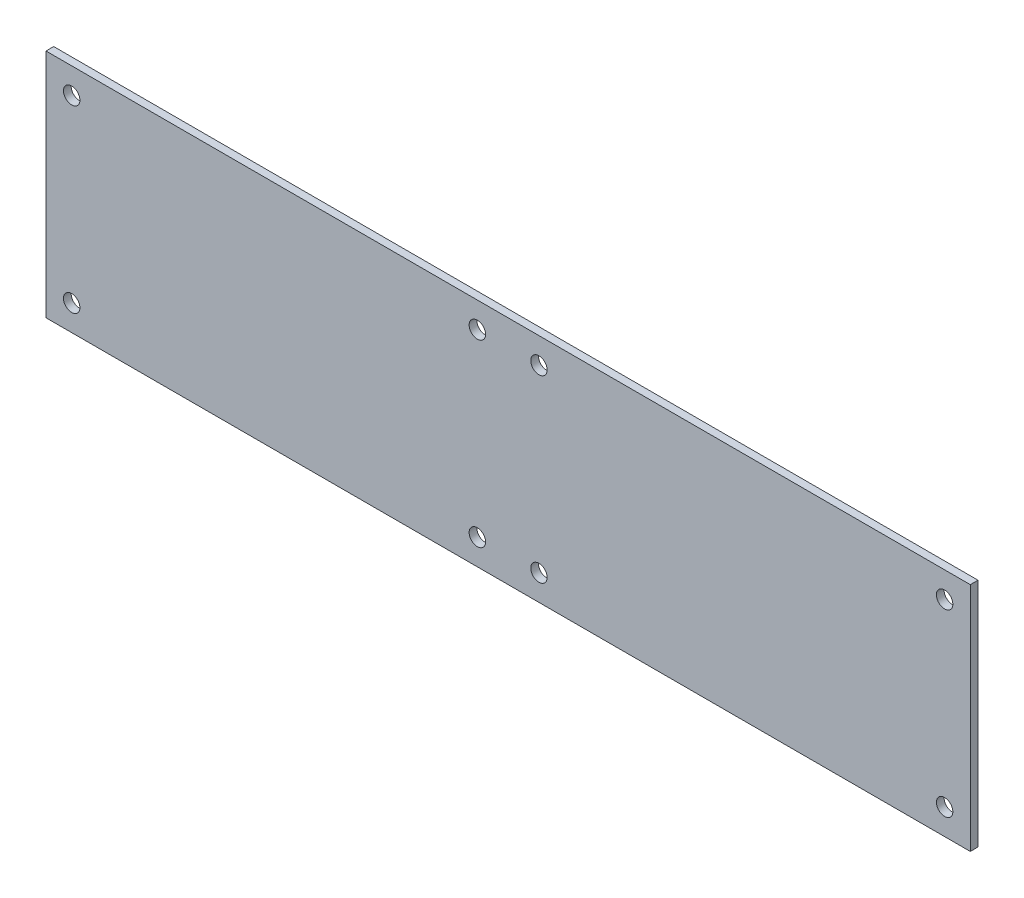
from build123d import *

# Parameters (mm, degrees)
ESQUISSE1_W = 180
ESQUISSE1_H = 45
ESQUISSE1_R = 1.6
MAIN_DEPTH  = 1.5


with BuildPart() as part:
    # Esquisse1 → Main (new body)
    with BuildSketch(Plane.XY):
        Rectangle(ESQUISSE1_W, ESQUISSE1_H)
        with Locations((-85, 17.5)):
            Circle(ESQUISSE1_R, mode=Mode.SUBTRACT)
        with Locations((-85, -17.5)):
            Circle(ESQUISSE1_R, mode=Mode.SUBTRACT)
        with Locations((85, -17.5)):
            Circle(ESQUISSE1_R, mode=Mode.SUBTRACT)
        with Locations((85, 17.5)):
            Circle(ESQUISSE1_R, mode=Mode.SUBTRACT)
        with Locations((-6, 17.5)):
            Circle(ESQUISSE1_R, mode=Mode.SUBTRACT)
        with Locations((-6, -17.5)):
            Circle(ESQUISSE1_R, mode=Mode.SUBTRACT)
        with Locations((6, -17.5)):
            Circle(ESQUISSE1_R, mode=Mode.SUBTRACT)
        with Locations((6, 17.5)):
            Circle(ESQUISSE1_R, mode=Mode.SUBTRACT)
    extrude(amount=MAIN_DEPTH)


solid = part.part
